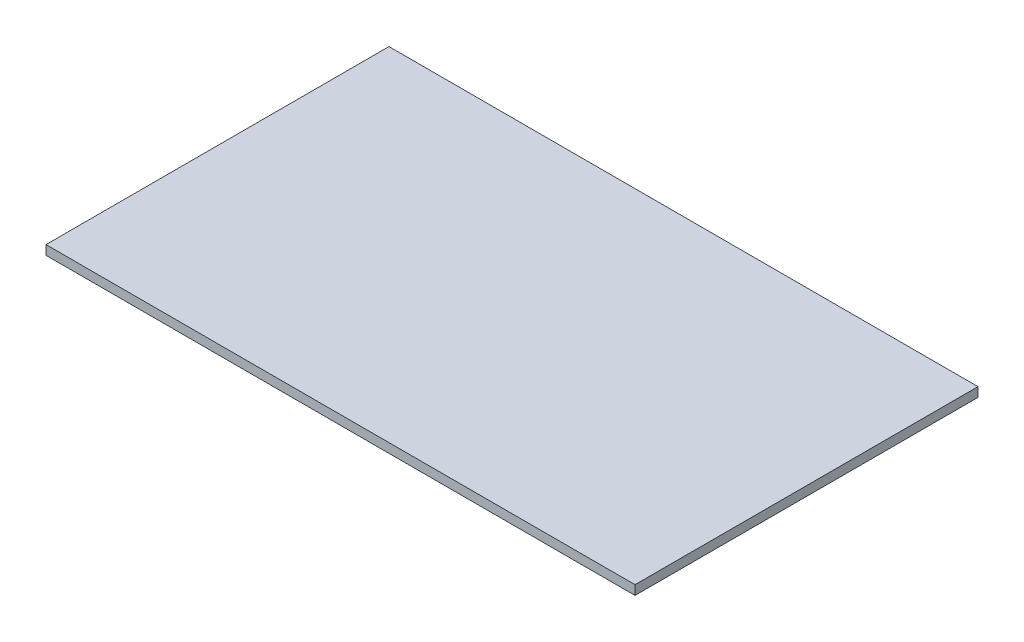
from build123d import *

# Parameters (mm, degrees)
SKETCH1_W           = 100.33
SKETCH1_H           = 58.42
BOSS_EXTRUDE1_DEPTH = 1.5875


with BuildPart() as part:
    # Sketch1 → Boss-Extrude1 (new body)
    with BuildSketch(Plane(origin=(0, 0, 0), x_dir=(1, 0, 0), z_dir=(0, 1, 0))):
        Rectangle(SKETCH1_W, SKETCH1_H)
    extrude(amount=BOSS_EXTRUDE1_DEPTH)


solid = part.part
